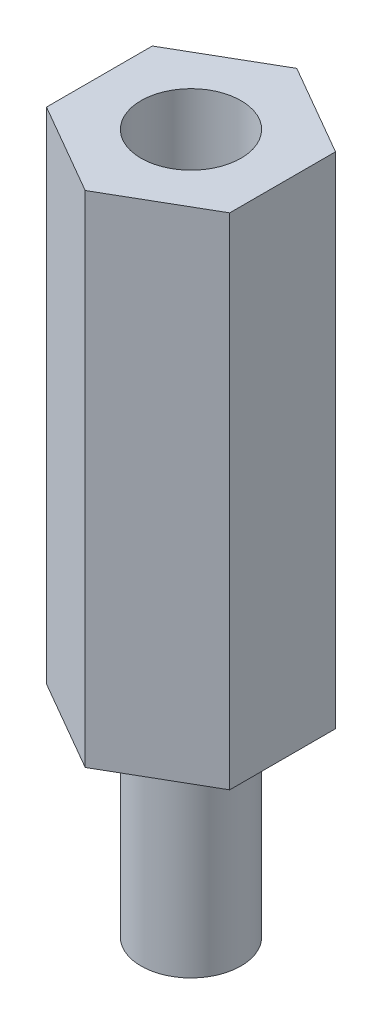
from build123d import *

# Parameters (mm, degrees)
SALIENTE_EXTRUIR1_DEPTH = 15
CROQUIS2_R              = 1.5
SALIENTE_EXTRUIR2_DEPTH = 6
CROQUIS3_R              = 1.5
CORTAR_EXTRUIR1_DEPTH   = 6


with BuildPart() as part:
    # Croquis1 → Saliente-Extruir1 (new body)
    with BuildSketch(Plane(origin=(0, 0, 0), x_dir=(1, 0, 0), z_dir=(0, 1, 0))):
        Polygon((0, 3.175426481), (-2.75, 1.58771324), (-2.75, -1.58771324), (0, -3.175426481), (2.75, -1.58771324), (2.75, 1.58771324), align=None)
    extrude(amount=SALIENTE_EXTRUIR1_DEPTH)

    # Croquis2 → Saliente-Extruir2 (add)
    with BuildSketch(Plane.XZ):
        Circle(CROQUIS2_R)
    extrude(amount=SALIENTE_EXTRUIR2_DEPTH)

    # Croquis3 → Cortar-Extruir1 (cut)
    with BuildSketch(Plane(origin=(0, 15, 0), x_dir=(1, 0, 0), z_dir=(0, 1, 0))):
        Circle(CROQUIS3_R)
    extrude(amount=-CORTAR_EXTRUIR1_DEPTH, mode=Mode.SUBTRACT)


solid = part.part
